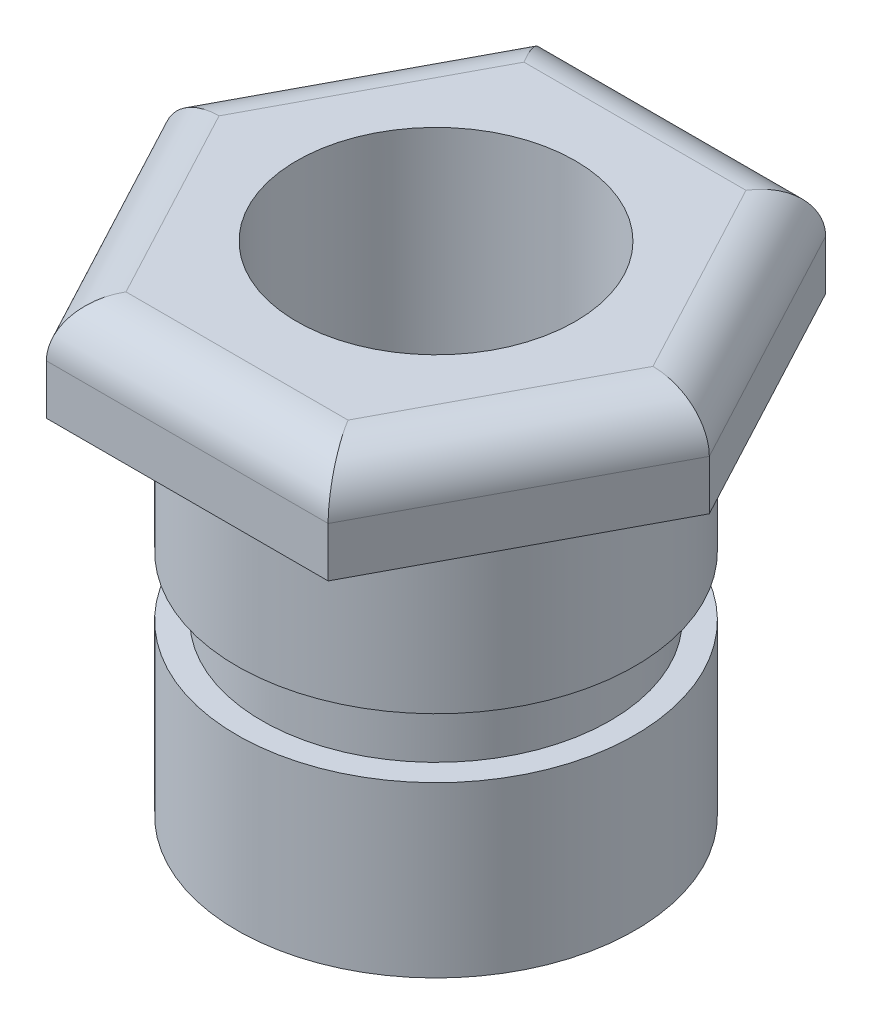
from build123d import *

# Parameters (mm, degrees)
BOSS_EXTRUDE1_DEPTH = 20
FILLET1_R           = 10
CUT_EXTRUDE1_REACH  = 102
SKETCH5_R           = 28


with BuildPart() as part:
    # Sketch1 → Revolve1 (revolve)
    with BuildSketch(Plane.XY):
        Polygon((0, 0), (40, 0), (40, 34), (35, 34), (35, 46), (40, 46), (40, 80), (0, 80), align=None)
    revolve(axis=Axis((0, 103.412132622, 0), (0, -1, 0)))

    # Sketch2 → Boss-Extrude1 (add)
    with BuildSketch(Plane(origin=(0, 80, 0), x_dir=(1, 0, 0), z_dir=(0, 1, 0))):
        Polygon((-28.321671813, 50), (28.321671813, 50), (54.938741093, 0), (28.321671813, -50), (-28.321671813, -50), (-54.938741093, 0), align=None)
    extrude(amount=BOSS_EXTRUDE1_DEPTH)

    # Fillet1
    fillet1_edges = [part.edges().sort_by_distance(p)[0] for p in [
        (-41.630206453, 100, -25),
        (-41.630206453, 100, 25),
        (0, 100, 50),
        (41.630206453, 100, 25),
        (41.630206453, 100, -25),
        (0, 100, -50),
    ]]
    fillet(fillet1_edges, radius=FILLET1_R)

    # Sketch5 → Cut-Extrude1 (cut, up to next)
    with BuildSketch(Plane.XZ, mode=Mode.PRIVATE) as cut_extrude1_sk1:
        Circle(SKETCH5_R)
    cut_extrude1_tool1 = extrude(cut_extrude1_sk1.sketch, amount=-CUT_EXTRUDE1_REACH, mode=Mode.PRIVATE) & part.part
    add(cut_extrude1_tool1.solids().sort_by_distance((0, 0, 0))[0], mode=Mode.SUBTRACT)


solid = part.part
